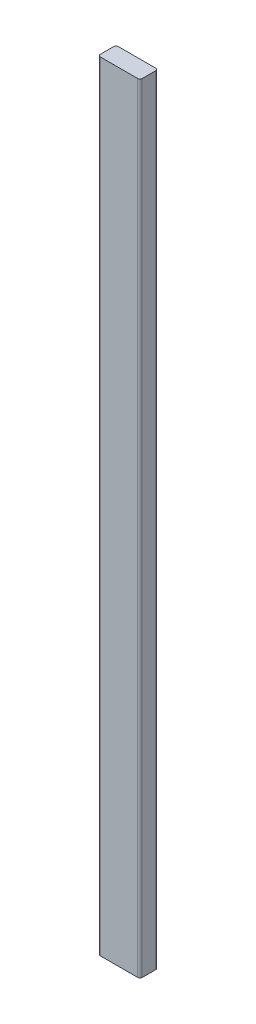
from build123d import *

# Parameters (mm, degrees)
SKETCH1_W           = 88.9
SKETCH1_H           = 1651
BOSS_EXTRUDE1_DEPTH = 38.1
FILLET1_R           = 4.7625


with BuildPart() as part:
    # Sketch1 → Boss-Extrude1 (new body)
    with BuildSketch(Plane.XY):
        with Locations((-503.382187925, 825.5)):
            Rectangle(SKETCH1_W, SKETCH1_H)
    extrude(amount=-BOSS_EXTRUDE1_DEPTH)

    # Fillet1
    fillet1_edges = [part.edges().sort_by_distance(p)[0] for p in [
        (-458.932187925, 825.5, -38.1),
        (-547.832187925, 825.5, -38.1),
        (-458.932187925, 825.5, 0),
        (-547.832187925, 825.5, 0),
    ]]
    fillet(fillet1_edges, radius=FILLET1_R)


solid = part.part
